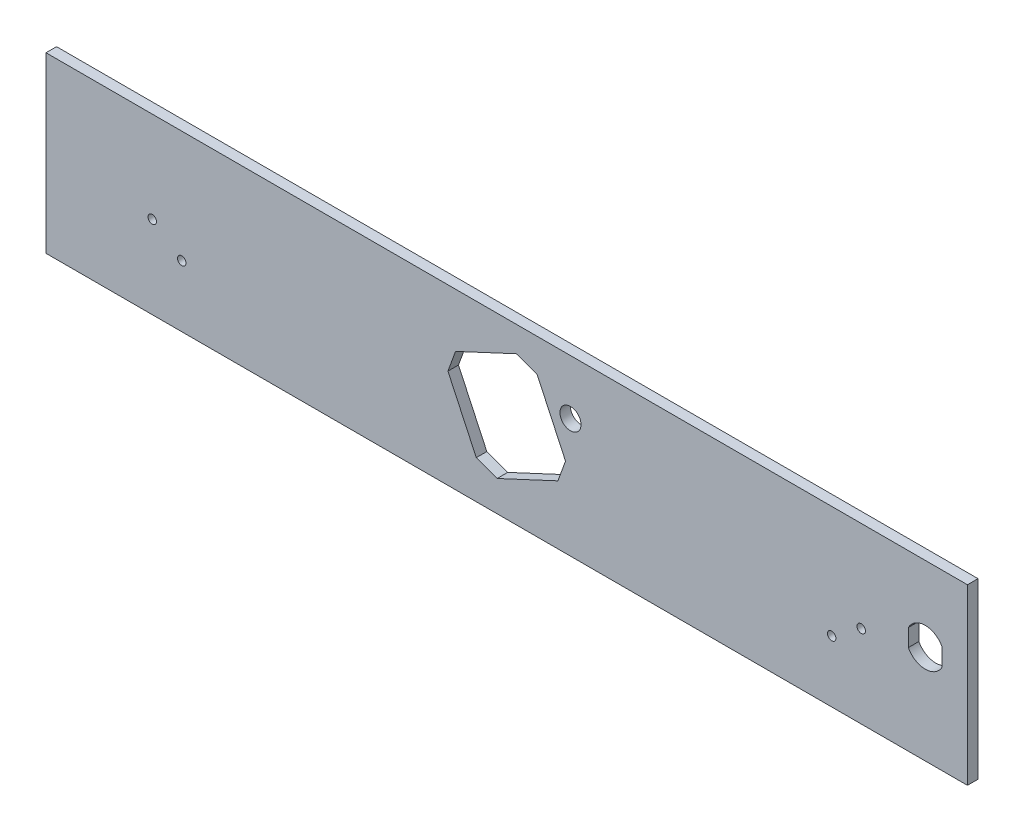
from build123d import *

# Parameters (mm, degrees)
SKETCH1_W           = 415.925
SKETCH1_H           = 78.4225
BOSS_EXTRUDE1_DEPTH = 4.7625
SKETCH2_R           = 1.905
CUT_EXTRUDE1_DEPTH  = 424.280492744
CUT_EXTRUDE2_DEPTH  = 424.280492744
SKETCH4_W           = 1.211538462
SKETCH4_H           = 0.583333334
CUT_EXTRUDE3_DEPTH  = 1.016
SKETCH5_R           = 4.7625
CUT_EXTRUDE4_DEPTH  = 424.280492862


with BuildPart() as part:
    # Sketch1 → Boss-Extrude1 (new body)
    with BuildSketch(Plane.XY):
        with Locations((207.9625, 39.21125)):
            Rectangle(SKETCH1_W, SKETCH1_H)
    extrude(amount=BOSS_EXTRUDE1_DEPTH)

    # Sketch2 → Cut-Extrude1 (cut, through all)
    with BuildSketch(Plane(origin=(0, 0, 0), x_dir=(-1, 0, 0), z_dir=(0, 0, -1))):
        with Locations((-367.9825, 37.30625)):
            Circle(SKETCH2_R)
        with Locations((-354.6475, 27.78125)):
            Circle(SKETCH2_R)
        with Locations((-47.9425, 37.30625)):
            Circle(SKETCH2_R)
        with Locations((-61.2775, 27.78125)):
            Circle(SKETCH2_R)
    extrude(amount=-CUT_EXTRUDE1_DEPTH, mode=Mode.SUBTRACT)

    # Sketch3 → Cut-Extrude2 (cut, through all)
    with BuildSketch(Plane.XY.offset(4.7625)):
        with BuildLine():
            ThreePointArc((404.495, 48.377258108), (396.875, 53.0225), (389.255, 48.377258108))
            Line((389.255, 48.377258108), (389.255, 40.522741892))
            ThreePointArc((389.255, 40.522741892), (396.875, 35.8775), (404.495, 40.522741892))
            Line((404.495, 40.522741892), (404.495, 48.377258108))
        make_face()
    extrude(amount=-CUT_EXTRUDE2_DEPTH, mode=Mode.SUBTRACT)

    # Sketch4 → Cut-Extrude3 (cut)
    # profile 1 of 9: a face of its own
    with BuildSketch(Plane.XY):
        Polygon((43.775641026, 9.85), (43.147435897, 9.85), (43.147435897, 6.978205128), (42.16025641, 6.978205128), (42.16025641, 6.35), (43.775641026, 6.35), align=None)
    # profile 2 of 9: a face of its own
    with BuildSketch(Plane.XY):
        with BuildLine():
            Line((38.480769231, 9.242828526), (38.94140625, 8.802524038))
            add(Edge.make_bspline(
                [(38.94140625, 8.802524038), (38.980481235, 8.842927638), (39.056806922, 8.921848526), (39.179796327, 9.026332827), (39.30770083, 9.113406355), (39.438032304, 9.186739125), (39.573135035, 9.242220593), (39.711446867, 9.282650872), (39.853850963, 9.307299686), (39.950224577, 9.310119946), (39.998697917, 9.311538462)],
                knots=[0, 0, 0, 0, 1.115251505, 2.178435587, 3.19620269, 4.182487026, 5.141301733, 6.088180966, 7.038406374, 8, 8, 8, 8], degree=3))
            add(Edge.make_bspline(
                [(39.998697917, 9.311538462), (40.039179046, 9.310417785), (40.119064094, 9.308206253), (40.236356279, 9.291993543), (40.348552316, 9.264423124), (40.456036269, 9.226425979), (40.558491863, 9.17725969), (40.656133908, 9.116962311), (40.748721672, 9.046078413), (40.835032124, 8.964974752), (40.913985892, 8.876362907), (40.983746573, 8.781814281), (41.042182334, 8.681545478), (41.090139613, 8.576571947), (41.127496479, 8.466407818), (41.154173975, 8.35112726), (41.169603525, 8.23059298), (41.171906489, 8.148654675), (41.173076923, 8.107011218)],
                knots=[0, 0, 0, 0, 1.035432265, 2.043311493, 3.022114605, 3.98653278, 4.95457646, 5.923598177, 6.917315552, 7.932509744, 8.948865224, 9.949768934, 10.933144597, 11.912367597, 12.897413939, 13.903909035, 14.934704909, 16, 16, 16, 16], degree=3))
            add(Edge.make_bspline(
                [(41.173076923, 8.107011218), (41.172739617, 8.077782926), (41.172074781, 8.020173362), (41.16479697, 7.934952828), (41.153077977, 7.852268764), (41.136117692, 7.772246412), (41.114908688, 7.694816425), (41.090025698, 7.61931082), (41.058810352, 7.546772912), (41.024160848, 7.476360221), (40.983863874, 7.409994047), (40.940416301, 7.346708391), (40.893304503, 7.286813475), (40.842223332, 7.23055415), (40.786453885, 7.178809624), (40.727437596, 7.130023877), (40.664178942, 7.085418182), (40.597991965, 7.04387311), (40.528304893, 7.007782552), (40.457008498, 6.975091479), (40.383021783, 6.948541467), (40.307245581, 6.927139735), (40.22995069, 6.908940759), (40.150381092, 6.89773509), (40.069226558, 6.889249168), (40.014379715, 6.888725212), (39.986778846, 6.888461538)],
                knots=[0, 0, 0, 0, 1.103660481, 2.175337485, 3.227646561, 4.255952547, 5.262355991, 6.258840057, 7.255597736, 8.242457506, 9.22035537, 10.185017736, 11.140346927, 12.096287581, 13.051739095, 14.01125915, 14.986044842, 15.97314143, 16.960198552, 17.947847494, 18.933482797, 19.925264591, 20.920966487, 21.929612487, 22.958107872, 24, 24, 24, 24], degree=3))
            add(Edge.make_bspline(
                [(39.986778846, 6.888461538), (39.939963029, 6.8898157), (39.847982123, 6.892476276), (39.712986917, 6.913281603), (39.584349935, 6.947505189), (39.481569602, 6.987921255), (39.401043925, 7.027832645), (39.339740919, 7.064748715), (39.276348831, 7.106043392), (39.211920552, 7.153275183), (39.145731391, 7.205877287), (39.07894974, 7.265001788), (39.009865975, 7.328701801), (38.964609885, 7.374165752), (38.94140625, 7.397475962)],
                knots=[0, 0, 0, 0, 1.404581149, 2.759636711, 4.088442092, 5.392261763, 6.066678138, 6.783632037, 7.538459478, 8.336747902, 9.180226004, 10.074962426, 11.012997595, 12, 12, 12, 12], degree=3))
            Line((38.94140625, 7.397475962), (38.494791667, 6.928425481))
            add(Edge.make_bspline(
                [(38.494791667, 6.928425481), (38.526186268, 6.898114979), (38.587461816, 6.838955361), (38.679894278, 6.754954225), (38.772210411, 6.679469865), (38.862180049, 6.609762532), (38.951276987, 6.547862968), (39.039491778, 6.493709355), (39.125825792, 6.445932068), (39.212071781, 6.405336849), (39.298766414, 6.370867291), (39.387965003, 6.341191265), (39.479940237, 6.316086414), (39.575253859, 6.295830096), (39.67301684, 6.279587264), (39.774144114, 6.268623446), (39.877994482, 6.261252837), (39.948437796, 6.260590526), (39.983974359, 6.26025641)],
                knots=[0, 0, 0, 0, 1.244526981, 2.429050516, 3.560637417, 4.644440555, 5.67424972, 6.652764056, 7.595344123, 8.486817594, 9.369275933, 10.254498637, 11.166417451, 12.086725134, 13.032340136, 13.991389299, 14.986715468, 16, 16, 16, 16], degree=3))
            add(Edge.make_bspline(
                [(39.983974359, 6.26025641), (40.049250623, 6.261920432), (40.176978127, 6.265176461), (40.364159453, 6.28930143), (40.541976689, 6.329746515), (40.71086243, 6.386947022), (40.870762974, 6.460017988), (41.021637415, 6.549599561), (41.163242575, 6.655453737), (41.294434564, 6.776339803), (41.413103962, 6.909848314), (41.517993967, 7.053199828), (41.604758983, 7.207098866), (41.676801845, 7.369271846), (41.733138416, 7.540458828), (41.772789812, 7.720844982), (41.797242538, 7.910256136), (41.799917701, 8.039628321), (41.801282051, 8.105608974)],
                knots=[0, 0, 0, 0, 1.078019885, 2.10938526, 3.111377082, 4.085535484, 5.04941344, 6.010039228, 6.978205633, 7.964457913, 8.951525778, 9.924444315, 10.892603023, 11.863865945, 12.85144698, 13.863884204, 14.910567087, 16, 16, 16, 16], degree=3))
            add(Edge.make_bspline(
                [(41.801282051, 8.105608974), (41.800705543, 8.148640994), (41.799563044, 8.233919938), (41.787555277, 8.359542733), (41.770815751, 8.482002487), (41.744260015, 8.600027663), (41.712249695, 8.715208277), (41.672440656, 8.826292451), (41.624896479, 8.933599451), (41.571149624, 9.037308917), (41.510346346, 9.13674144), (41.442422408, 9.231042737), (41.36912644, 9.320940799), (41.288697256, 9.405242959), (41.2023036, 9.484689407), (41.109555414, 9.558849608), (41.011010532, 9.628787103), (40.906402228, 9.692698373), (40.797762765, 9.750509514), (40.686462371, 9.801501409), (40.572774499, 9.844118891), (40.457179831, 9.879468521), (40.339189981, 9.905854519), (40.219647131, 9.925827869), (40.097534115, 9.936993099), (40.015545803, 9.938820919), (39.974158654, 9.93974359)],
                knots=[0, 0, 0, 0, 1.071919942, 2.124283339, 3.142214191, 4.149696895, 5.136002878, 6.119640489, 7.086990633, 8.058538607, 9.028339693, 9.988281803, 10.952401235, 11.916291999, 12.888973767, 13.874849856, 14.873389453, 15.898127285, 16.927174885, 17.938320013, 18.946391617, 19.950418109, 20.947802303, 21.956882652, 22.968648068, 24, 24, 24, 24], degree=3))
            add(Edge.make_bspline(
                [(39.974158654, 9.93974359), (39.938851172, 9.939214692), (39.868603307, 9.938162395), (39.763992448, 9.929390354), (39.660218217, 9.915613953), (39.557652159, 9.894828298), (39.455560616, 9.870153099), (39.355285185, 9.837844329), (39.255243968, 9.801830117), (39.157005961, 9.758782479), (39.060434039, 9.711792095), (38.967790552, 9.658479797), (38.877520024, 9.602126365), (38.791622796, 9.539396556), (38.708489827, 9.472565697), (38.628555828, 9.401321984), (38.552522265, 9.324477576), (38.504807823, 9.270182466), (38.480769231, 9.242828526)],
                knots=[0, 0, 0, 0, 0.996412454, 1.982464992, 2.961075852, 3.949442424, 4.934965278, 5.923860011, 6.921385422, 7.934793307, 8.949617135, 9.951082467, 10.950285876, 11.951772932, 12.951063433, 13.960125323, 14.972308753, 16, 16, 16, 16], degree=3))
        make_face()
    # profile 3 of 9: a face of its own
    with BuildSketch(Plane.XY):
        with BuildLine():
            Line((36.057692308, 9.382351763), (36.52744391, 8.952564103))
            add(Edge.make_bspline(
                [(36.52744391, 8.952564103), (36.547566055, 8.980948479), (36.586197766, 9.035442524), (36.64881574, 9.108411334), (36.711150962, 9.17065916), (36.77378093, 9.221925958), (36.837260772, 9.261900244), (36.901480295, 9.290202481), (36.966075423, 9.308194481), (37.009473377, 9.310434918), (37.030849359, 9.311538462)],
                knots=[0, 0, 0, 0, 1.299362458, 2.494594718, 3.587462134, 4.587049575, 5.512617175, 6.380583204, 7.202344345, 8, 8, 8, 8], degree=3))
            add(Edge.make_bspline(
                [(37.030849359, 9.311538462), (37.050788262, 9.310839206), (37.089285044, 9.309489126), (37.144165063, 9.296069437), (37.192888326, 9.272909025), (37.23540728, 9.242624837), (37.269088565, 9.206139412), (37.295980459, 9.167875583), (37.311122855, 9.125640968), (37.313115892, 9.096632532), (37.314102564, 9.082271635)],
                knots=[0, 0, 0, 0, 1.185010067, 2.2879431, 3.333075148, 4.379039566, 5.372662701, 6.27520591, 7.14612461, 8, 8, 8, 8], degree=3))
            add(Edge.make_bspline(
                [(37.314102564, 9.082271635), (37.313484267, 9.067703647), (37.312239103, 9.038365745), (37.300212509, 8.995367395), (37.282084998, 8.953353002), (37.264763421, 8.927776842), (37.255909455, 8.914703526)],
                knots=[0, 0, 0, 0, 0.967525499, 1.948461899, 2.951351359, 4, 4, 4, 4], degree=3))
            add(Edge.make_bspline(
                [(37.255909455, 8.914703526), (37.247860243, 8.904541774), (37.229332018, 8.881150764), (37.194002489, 8.84410305), (37.14963602, 8.798716357), (37.094525297, 8.746551401), (37.030958116, 8.685732126), (36.955988057, 8.618649361), (36.871773086, 8.543225631), (36.811915035, 8.490703276), (36.780548878, 8.46318109)],
                knots=[0, 0, 0, 0, 0.473873513, 1.090794244, 1.870441696, 2.795289791, 3.865433203, 5.087734844, 6.473946851, 8, 8, 8, 8], degree=3))
            add(Edge.make_bspline(
                [(36.780548878, 8.46318109), (36.751107228, 8.437700826), (36.695233092, 8.38934458), (36.615735292, 8.320710653), (36.545869966, 8.258962381), (36.484619336, 8.205026476), (36.432911902, 8.158337026), (36.390530284, 8.118670855), (36.356956864, 8.086800191), (36.337872341, 8.067550291), (36.329727564, 8.059334936)],
                knots=[0, 0, 0, 0, 1.543621617, 2.929473131, 4.163658386, 5.240097082, 6.164993805, 6.925417477, 7.541396219, 8, 8, 8, 8], degree=3))
            add(Edge.make_bspline(
                [(36.329727564, 8.059334936), (36.29882798, 8.025894968), (36.239428127, 7.961611605), (36.162229258, 7.861992611), (36.098692092, 7.764744159), (36.049538535, 7.668036363), (36.012415792, 7.570473922), (35.986243767, 7.469664122), (35.970569166, 7.364553564), (35.96882892, 7.292828439), (35.967948718, 7.256550481)],
                knots=[0, 0, 0, 0, 1.206664779, 2.319633467, 3.337109185, 4.282041471, 5.190008762, 6.099243693, 7.03861361, 8, 8, 8, 8], degree=3))
            add(Edge.make_bspline(
                [(35.967948718, 7.256550481), (35.968575223, 7.221202059), (35.96980445, 7.151847141), (35.984860117, 7.050356549), (36.006328616, 6.953225647), (36.039522681, 6.861511358), (36.07997941, 6.773708218), (36.130697764, 6.691183923), (36.190259516, 6.613103292), (36.258526428, 6.540862112), (36.33403774, 6.475308248), (36.415030799, 6.41695065), (36.502297595, 6.36876902), (36.595092535, 6.329094884), (36.693365947, 6.298537334), (36.797000759, 6.275952457), (36.906155487, 6.262397369), (36.980797062, 6.260980346), (37.018930288, 6.26025641)],
                knots=[0, 0, 0, 0, 1.043214005, 2.046824704, 3.02475056, 3.976699089, 4.921714032, 5.875962561, 6.831408892, 7.817874052, 8.806269674, 9.781291748, 10.760897367, 11.74438705, 12.757449933, 13.795994037, 14.874007457, 16, 16, 16, 16], degree=3))
            add(Edge.make_bspline(
                [(37.018930288, 6.26025641), (37.048864546, 6.260787464), (37.108151544, 6.261839255), (37.195531615, 6.270426251), (37.279906952, 6.284284751), (37.361182513, 6.30414812), (37.439724459, 6.329317702), (37.515536015, 6.360061383), (37.588093829, 6.396855678), (37.657946907, 6.43894395), (37.724755679, 6.487813977), (37.789364914, 6.542466629), (37.851132852, 6.603742487), (37.910356152, 6.671496636), (37.966655887, 6.74592094), (38.021874948, 6.825978902), (38.073559236, 6.91315629), (38.10548692, 6.974311933), (38.121794872, 7.005548878)],
                knots=[0, 0, 0, 0, 1.016823716, 2.013894106, 2.979844003, 3.91962641, 4.853723003, 5.779685073, 6.695824784, 7.614987388, 8.547259901, 9.504950863, 10.487499108, 11.500346958, 12.559593716, 13.656357062, 14.802919212, 16, 16, 16, 16], degree=3))
            Line((38.121794872, 7.005548878), (37.569310897, 7.337179487))
            add(Edge.make_bspline(
                [(37.569310897, 7.337179487), (37.548912087, 7.301721473), (37.509805823, 7.23374543), (37.443536604, 7.142411001), (37.375647172, 7.064198182), (37.304567985, 7.000489388), (37.231163338, 6.950432751), (37.15507867, 6.914658806), (37.076260527, 6.892514774), (37.022573188, 6.889810476), (36.995793269, 6.888461538)],
                knots=[0, 0, 0, 0, 1.283663364, 2.460892379, 3.537111102, 4.529833553, 5.449777664, 6.316464042, 7.160231139, 8, 8, 8, 8], degree=3))
            add(Edge.make_bspline(
                [(36.995793269, 6.888461538), (36.968554258, 6.889563154), (36.91570661, 6.891700449), (36.840273355, 6.911441996), (36.77111329, 6.942437673), (36.711331841, 6.98666423), (36.660712679, 7.037708399), (36.623352832, 7.094497371), (36.599883124, 7.155941668), (36.597401806, 7.198624918), (36.596153846, 7.220092147)],
                knots=[0, 0, 0, 0, 1.13588714, 2.203786484, 3.234766741, 4.283437687, 5.291419208, 6.222934724, 7.106237994, 8, 8, 8, 8], degree=3))
            add(Edge.make_bspline(
                [(36.596153846, 7.220092147), (36.597306286, 7.240063911), (36.599647359, 7.280634636), (36.616890974, 7.34095678), (36.643848006, 7.401251492), (36.675740074, 7.450706845), (36.708194248, 7.492114472), (36.739227757, 7.527992307), (36.777018363, 7.567631034), (36.821470244, 7.611080516), (36.871996075, 7.658723248), (36.928638418, 7.710554566), (36.992045887, 7.766117898), (37.036862411, 7.80396709), (37.060296474, 7.823758013)],
                knots=[0, 0, 0, 0, 0.916159276, 1.861089862, 2.860218735, 3.940849679, 4.552606315, 5.27541173, 6.11797699, 7.06649574, 8.129236253, 9.306560635, 10.591630461, 12, 12, 12, 12], degree=3))
            add(Edge.make_bspline(
                [(37.060296474, 7.823758013), (37.104845561, 7.861450812), (37.190348742, 7.933794702), (37.311175584, 8.04064435), (37.420051388, 8.140505137), (37.516035784, 8.23461156), (37.600351764, 8.321225691), (37.672428301, 8.401051045), (37.731473603, 8.474703364), (37.793606052, 8.561939606), (37.852644301, 8.668242962), (37.903670101, 8.796138223), (37.936773487, 8.924017255), (37.940482261, 9.009868194), (37.942307692, 9.052123397)],
                knots=[0, 0, 0, 0, 1.345494975, 2.582412109, 3.71882943, 4.751509156, 5.681369928, 6.505683931, 7.230279997, 7.856715994, 8.973648664, 10.023341002, 11.027102913, 12, 12, 12, 12], degree=3))
            add(Edge.make_bspline(
                [(37.942307692, 9.052123397), (37.941548498, 9.08208852), (37.940052803, 9.14112303), (37.926710976, 9.227924675), (37.906771107, 9.311680969), (37.877812692, 9.392086331), (37.840228166, 9.469040051), (37.79458322, 9.542918848), (37.740169073, 9.613042759), (37.678848003, 9.679365297), (37.611287883, 9.739976549), (37.53909131, 9.793472052), (37.462666922, 9.838655132), (37.382482245, 9.876137778), (37.298040408, 9.904828362), (37.209963489, 9.925165678), (37.11812516, 9.937261665), (37.05565871, 9.938905974), (37.023838141, 9.93974359)],
                knots=[0, 0, 0, 0, 1.010766082, 1.991317756, 2.957454644, 3.913069143, 4.869106762, 5.843196583, 6.838735724, 7.860187025, 8.887984031, 9.89767229, 10.887916223, 11.879572884, 12.879850636, 13.892031539, 14.926195476, 16, 16, 16, 16], degree=3))
            add(Edge.make_bspline(
                [(37.023838141, 9.93974359), (36.982600258, 9.93823502), (36.900450011, 9.935229789), (36.7789885, 9.911729864), (36.660349974, 9.874773756), (36.564748827, 9.830190278), (36.488680779, 9.787002242), (36.430381725, 9.747240139), (36.371059301, 9.701690512), (36.310235106, 9.650209824), (36.249039349, 9.59182811), (36.185731941, 9.527935192), (36.121175524, 9.457978887), (36.079224089, 9.408002427), (36.057692308, 9.382351763)],
                knots=[0, 0, 0, 0, 1.282922637, 2.555718331, 3.837320111, 5.142675274, 5.830281639, 6.55870424, 7.337177975, 8.157850921, 9.037902056, 9.96903443, 10.957596896, 12, 12, 12, 12], degree=3))
        make_face()
    # profile 4 of 9: a face of its own
    with BuildSketch(Plane.XY):
        Polygon((34.262119391, 9.85), (33.679487179, 9.85), (32.266025641, 6.35), (32.936999199, 6.35), (33.209034455, 7.067948718), (34.733974359, 7.067948718), (35.006009615, 6.35), (35.676282051, 6.35), align=None)
        Polygon((33.971153846, 8.911197917), (34.495592949, 7.696153846), (33.446714744, 7.696153846), align=None, mode=Mode.SUBTRACT)
    # profile 5 of 9: a face of its own
    with BuildSketch(Plane.XY):
        with BuildLine():
            Line((31.75, 9.85), (31.048878205, 9.85))
            add(Edge.make_bspline(
                [(31.048878205, 9.85), (31.003067817, 9.849794943), (30.914689975, 9.849399345), (30.787241855, 9.844602193), (30.669664725, 9.836005403), (30.561985597, 9.825381131), (30.464248747, 9.810486316), (30.376331777, 9.793410575), (30.298216444, 9.772607354), (30.229021881, 9.747914219), (30.166921996, 9.718801977), (30.108155475, 9.687795361), (30.054050449, 9.650790059), (30.001876074, 9.611774345), (29.954615248, 9.567021062), (29.909319558, 9.519508606), (29.867907401, 9.467352673), (29.830186887, 9.411184597), (29.795968569, 9.352042122), (29.766073157, 9.28981952), (29.741823673, 9.22441833), (29.721481371, 9.156261623), (29.705142236, 9.085352371), (29.694266388, 9.011254473), (29.686878965, 8.934485311), (29.686227126, 8.882236171), (29.685897436, 8.855809295)],
                knots=[0, 0, 0, 0, 1.698747864, 3.27724071, 4.728299578, 6.070144658, 7.288476769, 8.393259625, 9.389771311, 10.283485332, 11.113357557, 11.931608583, 12.74405601, 13.541433047, 14.344816069, 15.154114104, 15.974336324, 16.810834471, 17.661136416, 18.50621059, 19.367396281, 20.244825668, 21.142564693, 22.063065223, 23.020325768, 24, 24, 24, 24], degree=3))
            add(Edge.make_bspline(
                [(29.685897436, 8.855809295), (29.686374457, 8.826573871), (29.687311861, 8.769122669), (29.696501448, 8.684906257), (29.712200165, 8.604613532), (29.732717566, 8.527567372), (29.761327624, 8.455035358), (29.794013271, 8.385286853), (29.834226985, 8.320277391), (29.880177582, 8.259193782), (29.930360876, 8.201539387), (29.985968216, 8.148978868), (30.045939703, 8.101153923), (30.109928184, 8.057563341), (30.178173889, 8.018295054), (30.250627576, 7.982981357), (30.327784001, 7.952751692), (30.381513414, 7.936941821), (30.408754006, 7.928926282)],
                knots=[0, 0, 0, 0, 1.102006807, 2.165578795, 3.188629044, 4.184801286, 5.166646146, 6.124351954, 7.085497154, 8.042432466, 9.003981491, 9.963833307, 10.922997304, 11.89326795, 12.880200226, 13.889073926, 14.929769137, 16, 16, 16, 16], degree=3))
            add(Edge.make_bspline(
                [(30.408754006, 7.928926282), (30.426696227, 7.924462228), (30.465564856, 7.914791651), (30.529881759, 7.904973587), (30.604000238, 7.895946482), (30.688159965, 7.888188777), (30.782409461, 7.882915346), (30.886657467, 7.87879703), (31.000951227, 7.87580259), (31.080426588, 7.875696334), (31.121794872, 7.875641026)],
                knots=[0, 0, 0, 0, 0.618981996, 1.340914327, 2.176866532, 3.120127938, 4.170906482, 5.338178032, 6.614476169, 8, 8, 8, 8], degree=3))
            Line((31.121794872, 7.875641026), (31.121794872, 6.35))
            Line((31.121794872, 6.35), (31.75, 6.35))
            Line((31.75, 6.35), (31.75, 9.85))
        make_face()
        with BuildLine():
            Line((31.121794872, 8.503846154), (30.899539263, 8.503846154))
            add(Edge.make_bspline(
                [(30.899539263, 8.503846154), (30.859096346, 8.504102593), (30.784680778, 8.504574446), (30.68305539, 8.511397707), (30.601387274, 8.521818204), (30.536867946, 8.536763608), (30.485923825, 8.559445236), (30.441987711, 8.585683609), (30.404302583, 8.618861312), (30.37167281, 8.656772514), (30.345586289, 8.700334385), (30.327496646, 8.748837605), (30.315745969, 8.801263069), (30.314660685, 8.837747722), (30.314102564, 8.856510417)],
                knots=[0, 0, 0, 0, 1.8619151, 3.425951444, 4.686033666, 5.651700536, 6.461346321, 7.243864085, 7.999046032, 8.762387399, 9.539336099, 10.322741239, 11.137448474, 12, 12, 12, 12], degree=3))
            add(Edge.make_bspline(
                [(30.314102564, 8.856510417), (30.314654944, 8.872903138), (30.315726694, 8.904708959), (30.323600062, 8.950612649), (30.336147946, 8.993404356), (30.354329347, 9.03263718), (30.377833594, 9.068244457), (30.406490027, 9.100212159), (30.439930929, 9.129224904), (30.46574926, 9.144581793), (30.478866186, 9.152383814)],
                knots=[0, 0, 0, 0, 1.102301479, 2.1387299, 3.123554645, 4.094223062, 5.036071848, 5.982632524, 6.975082478, 8, 8, 8, 8], degree=3))
            add(Edge.make_bspline(
                [(30.478866186, 9.152383814), (30.489976979, 9.158002861), (30.513500806, 9.169899535), (30.553564164, 9.183730288), (30.599796666, 9.195398051), (30.652510436, 9.205082183), (30.711495182, 9.212598074), (30.77674038, 9.218345851), (30.848342046, 9.220657256), (30.89813672, 9.221405207), (30.924078526, 9.221794872)],
                knots=[0, 0, 0, 0, 0.656809284, 1.390599849, 2.23162475, 3.173112763, 4.218524733, 5.370385145, 6.63003504, 8, 8, 8, 8], degree=3))
            Line((30.924078526, 9.221794872), (31.121794872, 9.221794872))
            Line((31.121794872, 9.221794872), (31.121794872, 8.503846154))
        make_face(mode=Mode.SUBTRACT)
    # profile 6 of 9: a face of its own
    with BuildSketch(Plane.XY):
        with Locations((28.451923077, 7.628846154)):
            Rectangle(SKETCH4_W, SKETCH4_H)
    # profile 7 of 9: a face of its own
    with BuildSketch(Plane.XY):
        with BuildLine():
            Line((26.065304487, 9.93974359), (25.509314904, 9.657892628))
            Line((25.509314904, 9.657892628), (26.119290865, 8.458974359))
            add(Edge.make_bspline(
                [(26.119290865, 8.458974359), (26.083254058, 8.458041348), (26.012273656, 8.456203629), (25.907840397, 8.441350882), (25.808000257, 8.415674043), (25.711746553, 8.381639463), (25.620255895, 8.335930683), (25.532054775, 8.281557705), (25.449425001, 8.21524401), (25.370471942, 8.141771954), (25.298680331, 8.060375475), (25.236316625, 7.972912373), (25.181967756, 7.881510636), (25.139719132, 7.784125384), (25.105639986, 7.68237089), (25.081050382, 7.575840396), (25.067021324, 7.464225415), (25.065087185, 7.388400302), (25.064102564, 7.349799679)],
                knots=[0, 0, 0, 0, 1.013260694, 1.995783107, 2.958651975, 3.908806537, 4.861209129, 5.829647963, 6.817170299, 7.835534541, 8.860094905, 9.863329007, 10.853101798, 11.844815043, 12.84250023, 13.867713965, 14.914507806, 16, 16, 16, 16], degree=3))
            add(Edge.make_bspline(
                [(25.064102564, 7.349799679), (25.065025235, 7.312591021), (25.066848961, 7.239045459), (25.081924466, 7.131025732), (25.106287273, 7.027387122), (25.141106618, 6.928336607), (25.185364821, 6.833390025), (25.239489605, 6.742603092), (25.30392983, 6.656654229), (25.37702054, 6.576000127), (25.456921295, 6.502483317), (25.541141042, 6.437137297), (25.63039345, 6.383159006), (25.722991543, 6.337573073), (25.820640109, 6.303556092), (25.921877832, 6.277879165), (26.027472427, 6.263062463), (26.099147333, 6.261199246), (26.135416667, 6.26025641)],
                knots=[0, 0, 0, 0, 1.049934834, 2.075270938, 3.072134561, 4.05064612, 5.033440221, 6.024524368, 7.028587226, 8.060776465, 9.092543989, 10.090062252, 11.064205434, 12.031961459, 12.998029633, 13.977230324, 14.976426867, 16, 16, 16, 16], degree=3))
            add(Edge.make_bspline(
                [(26.135416667, 6.26025641), (26.173343368, 6.261030145), (26.247921094, 6.26255159), (26.357046971, 6.279587767), (26.46170808, 6.305233356), (26.561316207, 6.3418509), (26.656490786, 6.388476396), (26.746111308, 6.446170758), (26.830932701, 6.514297771), (26.910050646, 6.591324685), (26.981330018, 6.675697131), (27.044905261, 6.763297697), (27.098689998, 6.854263848), (27.142227489, 6.948498322), (27.17619645, 7.045700839), (27.199831918, 7.14605588), (27.215232606, 7.249297254), (27.217037986, 7.319362693), (27.217948718, 7.354707532)],
                knots=[0, 0, 0, 0, 1.063775006, 2.091769615, 3.092589432, 4.084662827, 5.064601646, 6.061867366, 7.070035304, 8.113879863, 9.156342271, 10.166834137, 11.149076039, 12.117706134, 13.076241869, 14.034148791, 15.008317125, 16, 16, 16, 16], degree=3))
            add(Edge.make_bspline(
                [(27.217948718, 7.354707532), (27.217467505, 7.382077976), (27.2165024, 7.436971218), (27.206803676, 7.519170865), (27.192058209, 7.601586278), (27.174966282, 7.671131014), (27.157366743, 7.729938366), (27.139652671, 7.779705439), (27.117699982, 7.834936007), (27.092604806, 7.895771109), (27.063577992, 7.962137558), (27.030771171, 8.033854458), (26.994102669, 8.111464902), (26.967952976, 8.16477126), (26.954326923, 8.192548077)],
                knots=[0, 0, 0, 0, 1.110454016, 2.227089276, 3.35462975, 4.507227546, 5.131400587, 5.845402449, 6.650387134, 7.543487832, 8.516250726, 9.590168902, 10.744287919, 12, 12, 12, 12], degree=3))
            Line((26.954326923, 8.192548077), (26.065304487, 9.93974359))
        make_face()
        with BuildLine():
            add(Edge.make_bspline(
                [(26.149439103, 7.875641026), (26.179582297, 7.874258421), (26.238568571, 7.871552845), (26.322438231, 7.843218739), (26.398908332, 7.798769578), (26.465193561, 7.736865525), (26.520635057, 7.662887751), (26.561375413, 7.578506218), (26.585883001, 7.484846975), (26.588429183, 7.419361994), (26.58974359, 7.385556891)],
                knots=[0, 0, 0, 0, 0.981744412, 1.921144944, 2.858899012, 3.85339082, 4.86292663, 5.863643845, 6.897155691, 8, 8, 8, 8], degree=3))
            add(Edge.make_bspline(
                [(26.58974359, 7.385556891), (26.588187291, 7.351740531), (26.585160185, 7.285965451), (26.559731079, 7.191414405), (26.518095742, 7.105116665), (26.459704838, 7.030158525), (26.391154756, 6.967937465), (26.315140845, 6.921922016), (26.232931045, 6.893653216), (26.176064519, 6.890204047), (26.147335737, 6.888461538)],
                knots=[0, 0, 0, 0, 1.098279937, 2.136227893, 3.159405121, 4.194678092, 5.206500211, 6.154139736, 7.067477469, 8, 8, 8, 8], degree=3))
            add(Edge.make_bspline(
                [(26.147335737, 6.888461538), (26.116994896, 6.890235082), (26.057491238, 6.89371331), (25.971653308, 6.920792611), (25.893239844, 6.96603715), (25.823907174, 7.028059004), (25.764351728, 7.102161771), (25.723145376, 7.188966412), (25.696540671, 7.284199894), (25.693750321, 7.351013724), (25.692307692, 7.385556891)],
                knots=[0, 0, 0, 0, 0.96921794, 1.900804717, 2.848419905, 3.844199796, 4.861108892, 5.867439427, 6.897452859, 8, 8, 8, 8], degree=3))
            add(Edge.make_bspline(
                [(25.692307692, 7.385556891), (25.69395111, 7.419342255), (25.697133779, 7.484771558), (25.7210394, 7.578869573), (25.763721271, 7.662925868), (25.820417175, 7.737170894), (25.888983591, 7.799047343), (25.968514181, 7.843569279), (26.056215147, 7.871502646), (26.11791138, 7.874241453), (26.149439103, 7.875641026)],
                knots=[0, 0, 0, 0, 1.083229974, 2.097801324, 3.086792542, 4.086858909, 5.079819718, 6.026392613, 6.991456328, 8, 8, 8, 8], degree=3))
        make_face(mode=Mode.SUBTRACT)
    # profile 8 of 9: a face of its own
    with BuildSketch(Plane.XY):
        with BuildLine():
            add(Edge.make_bspline(
                [(23.436798878, 9.93974359), (23.406391143, 9.939292178), (23.34660141, 9.938404583), (23.258542389, 9.928791201), (23.173717204, 9.914268063), (23.09179401, 9.894013349), (23.013362498, 9.867206957), (22.937851827, 9.835120165), (22.866160792, 9.796069956), (22.797375104, 9.751960738), (22.73152126, 9.702022851), (22.670182009, 9.64509108), (22.612237168, 9.58247543), (22.558941028, 9.513229263), (22.50911333, 9.437982447), (22.462917801, 9.35672305), (22.420708077, 9.269053361), (22.382011089, 9.174815174), (22.34740812, 9.072595899), (22.318262082, 8.961223037), (22.293264478, 8.840671153), (22.272164736, 8.710640176), (22.256216741, 8.570957264), (22.245467472, 8.421715214), (22.238090814, 8.263201744), (22.237488783, 8.154462806), (22.237179487, 8.098597756)],
                knots=[0, 0, 0, 0, 0.879237366, 1.728815576, 2.559023295, 3.367336655, 4.166867292, 4.954216142, 5.737608147, 6.525189134, 7.316157332, 8.124696809, 8.942788509, 9.781158001, 10.649253743, 11.551476218, 12.482711956, 13.461909668, 14.496590415, 15.601789533, 16.789733467, 18.056700938, 19.410929216, 20.8549011, 22.384193279, 24, 24, 24, 24], degree=3))
            add(Edge.make_bspline(
                [(22.237179487, 8.098597756), (22.237513753, 8.042033772), (22.238163224, 7.932130965), (22.245160822, 7.77216765), (22.257211017, 7.621842014), (22.272742177, 7.481169608), (22.294015618, 7.350224719), (22.318929775, 7.228668289), (22.348535875, 7.116544378), (22.384278654, 7.014105625), (22.422741408, 6.919701935), (22.465066594, 6.832203181), (22.510516488, 6.751372369), (22.558048608, 6.675990055), (22.61026884, 6.608278471), (22.664635477, 6.545935071), (22.723515739, 6.491334593), (22.784430541, 6.441663175), (22.849611437, 6.398737102), (22.918386235, 6.361194666), (22.991981069, 6.330743291), (23.069054431, 6.304258312), (23.150920052, 6.285244955), (23.236277098, 6.27015848), (23.326089234, 6.261820769), (23.387236953, 6.260786421), (23.418569712, 6.26025641)],
                knots=[0, 0, 0, 0, 1.643780988, 3.193836972, 4.651895693, 6.025988579, 7.305620092, 8.505800249, 9.631074763, 10.672816429, 11.65661981, 12.592235626, 13.49536222, 14.350718032, 15.179365177, 15.97804903, 16.751647189, 17.51006938, 18.259804725, 19.016521909, 19.783502495, 20.571750527, 21.382245291, 22.22305063, 23.089471752, 24, 24, 24, 24], degree=3))
            add(Edge.make_bspline(
                [(23.418569712, 6.26025641), (23.449901624, 6.260796645), (23.511280381, 6.261854957), (23.601335378, 6.270096486), (23.687144773, 6.28530607), (23.769658083, 6.304404282), (23.848301026, 6.33068469), (23.923450695, 6.362047148), (23.994529252, 6.399355338), (24.061733503, 6.442381425), (24.124833993, 6.491720504), (24.184811305, 6.546844838), (24.241532764, 6.607614701), (24.294135496, 6.674710765), (24.343480983, 6.747237439), (24.389054628, 6.826022941), (24.430829044, 6.910952561), (24.470110941, 7.002144684), (24.504241937, 7.10156257), (24.534616939, 7.210094009), (24.559499341, 7.3286437), (24.579511434, 7.457173557), (24.595489078, 7.595411285), (24.607374609, 7.743423606), (24.614411075, 7.901279462), (24.615053736, 8.009781655), (24.615384615, 8.065645032)],
                knots=[0, 0, 0, 0, 0.917216111, 1.796812873, 2.643793957, 3.46689424, 4.273913431, 5.068098542, 5.848489301, 6.620921603, 7.401012384, 8.190319798, 9.003608147, 9.831726257, 10.68377682, 11.569763213, 12.493818149, 13.453288342, 14.474581811, 15.568529029, 16.750744269, 18.018426408, 19.375425659, 20.823733699, 22.36466933, 24, 24, 24, 24], degree=3))
            add(Edge.make_bspline(
                [(24.615384615, 8.065645032), (24.614785258, 8.143262797), (24.613628789, 8.293027275), (24.598973169, 8.509393402), (24.577462435, 8.709386406), (24.545868263, 8.892671749), (24.506802506, 9.059928265), (24.45677677, 9.210054156), (24.399826109, 9.345126752), (24.351296829, 9.425144571), (24.327924679, 9.463681891)],
                knots=[0, 0, 0, 0, 1.288568992, 2.486310467, 3.599230591, 4.627010532, 5.572937695, 6.447898582, 7.252493626, 8, 8, 8, 8], degree=3))
            add(Edge.make_bspline(
                [(24.327924679, 9.463681891), (24.300748658, 9.501540942), (24.24761418, 9.575562848), (24.15470706, 9.672739774), (24.054890456, 9.755850239), (23.946114192, 9.82301338), (23.830098609, 9.875978238), (23.705847656, 9.913386721), (23.573820169, 9.935182647), (23.483154692, 9.938200572), (23.436798878, 9.93974359)],
                knots=[0, 0, 0, 0, 1.058512271, 2.069600068, 3.047294572, 4.004278952, 4.967380941, 5.939006123, 6.946246673, 8, 8, 8, 8], degree=3))
        make_face()
        with BuildLine():
            add(Edge.make_bspline(
                [(23.421374199, 9.311538462), (23.448863044, 9.310235545), (23.502755772, 9.307681137), (23.580956689, 9.285997815), (23.654695271, 9.252506756), (23.71078624, 9.212205503), (23.752769773, 9.173571918), (23.782103969, 9.138609781), (23.810392177, 9.099594555), (23.835377747, 9.054765685), (23.858970647, 9.005733924), (23.882028022, 8.952276698), (23.900929015, 8.893080981), (23.91949874, 8.829154885), (23.935767551, 8.758731022), (23.949397248, 8.681233756), (23.961574185, 8.596159114), (23.970067743, 8.503451372), (23.977986289, 8.403207526), (23.983662677, 8.295204271), (23.986035832, 8.179470744), (23.986790186, 8.099766781), (23.987179487, 8.058633814)],
                knots=[0, 0, 0, 0, 1.076674018, 2.110852608, 3.161083442, 4.239746716, 4.804137807, 5.395870207, 6.026861976, 6.692161227, 7.405688833, 8.16177676, 8.973626916, 9.841385931, 10.773283133, 11.807421078, 12.927755683, 14.143907515, 15.458935494, 16.872852025, 18.386167141, 20, 20, 20, 20], degree=3))
            add(Edge.make_bspline(
                [(23.987179487, 8.058633814), (23.986538745, 8.005344067), (23.985310075, 7.903157026), (23.978874876, 7.756208503), (23.965976054, 7.622473515), (23.949932523, 7.501045689), (23.927398728, 7.392712518), (23.901472139, 7.29644907), (23.869455107, 7.21348247), (23.832453257, 7.142612834), (23.791472041, 7.082324181), (23.746985128, 7.031078555), (23.700507138, 6.986702261), (23.650587343, 6.950655944), (23.597344835, 6.923031708), (23.541224092, 6.903161936), (23.48218945, 6.890998822), (23.441763136, 6.889312189), (23.421374199, 6.888461538)],
                knots=[0, 0, 0, 0, 1.771748488, 3.397459088, 4.888034009, 6.237357457, 7.467047327, 8.564189669, 9.548206622, 10.417051504, 11.216568818, 11.965764335, 12.669334354, 13.348544111, 14.005342236, 14.656555988, 15.322436492, 16, 16, 16, 16], degree=3))
            add(Edge.make_bspline(
                [(23.421374199, 6.888461538), (23.401684945, 6.889043617), (23.363135835, 6.890183253), (23.3069226, 6.901881469), (23.25376337, 6.920900227), (23.20381865, 6.947803595), (23.156909795, 6.982015344), (23.113266066, 7.023685815), (23.073216616, 7.073230366), (23.049883624, 7.109999749), (23.037860577, 7.128946314)],
                knots=[0, 0, 0, 0, 0.992283464, 1.942767638, 2.88273346, 3.832339453, 4.79467288, 5.803907806, 6.868395428, 8, 8, 8, 8], degree=3))
            add(Edge.make_bspline(
                [(23.037860577, 7.128946314), (23.023705464, 7.154836189), (22.99402334, 7.209125158), (22.959675134, 7.300735767), (22.930762729, 7.404057394), (22.905878245, 7.519411585), (22.888858776, 7.64725331), (22.87420163, 7.786771915), (22.867132124, 7.938669958), (22.86598223, 8.04390547), (22.865384615, 8.098597756)],
                knots=[0, 0, 0, 0, 0.710965849, 1.490837728, 2.352621235, 3.297892224, 4.334225155, 5.461620853, 6.680770821, 8, 8, 8, 8], degree=3))
            add(Edge.make_bspline(
                [(22.865384615, 8.098597756), (22.865615461, 8.153764798), (22.8660598, 8.259951935), (22.874212127, 8.412396063), (22.885564865, 8.551628473), (22.902170643, 8.677338316), (22.923536996, 8.789830761), (22.949871106, 8.889098454), (22.980917063, 8.975337033), (23.017733867, 9.048460505), (23.058510766, 9.110605426), (23.101796689, 9.163920947), (23.147774667, 9.209440394), (23.196367809, 9.247335064), (23.24870082, 9.276289435), (23.303774073, 9.296733616), (23.361700471, 9.309101659), (23.401214475, 9.310715231), (23.421374199, 9.311538462)],
                knots=[0, 0, 0, 0, 1.793836731, 3.452829483, 4.963243077, 6.335886805, 7.574563692, 8.684454726, 9.672768357, 10.54971625, 11.340229787, 12.085688095, 12.778991901, 13.440269426, 14.083255152, 14.715733572, 15.344777694, 16, 16, 16, 16], degree=3))
        make_face(mode=Mode.SUBTRACT)
    # profile 9 of 9: a face of its own
    with BuildSketch(Plane.XY):
        with BuildLine():
            Line((21.25, 8.683333333), (21.878205128, 8.683333333))
            add(Edge.make_bspline(
                [(21.878205128, 8.683333333), (21.875492007, 8.730853728), (21.87019073, 8.823705726), (21.849103591, 8.958576225), (21.820847549, 9.086014017), (21.783136109, 9.205573308), (21.735749217, 9.317210656), (21.679906261, 9.421306638), (21.614180579, 9.517313186), (21.53997103, 9.604767303), (21.458537488, 9.683223199), (21.371570593, 9.752787125), (21.27774007, 9.810189525), (21.178760279, 9.857426387), (21.074648073, 9.895166444), (20.964418389, 9.920398727), (20.849025654, 9.937486275), (20.770029983, 9.938981504), (20.729767628, 9.93974359)],
                knots=[0, 0, 0, 0, 1.199038563, 2.342849363, 3.436047546, 4.486744587, 5.497670872, 6.488682221, 7.459191391, 8.424610317, 9.374430501, 10.305433194, 11.225809216, 12.140057399, 13.06607119, 14.010487599, 14.985989317, 16, 16, 16, 16], degree=3))
            add(Edge.make_bspline(
                [(20.729767628, 9.93974359), (20.680346159, 9.93820151), (20.583863868, 9.935191008), (20.443667448, 9.909510428), (20.312739319, 9.866555691), (20.191174656, 9.806536594), (20.080008358, 9.730288623), (19.979258862, 9.639375396), (19.891972991, 9.531889507), (19.817597328, 9.412303267), (19.755800041, 9.28567827), (19.712495077, 9.154742772), (19.68403119, 9.02297127), (19.68099534, 8.934243011), (19.679487179, 8.890164263)],
                knots=[0, 0, 0, 0, 1.075374347, 2.099382735, 3.09057751, 4.06680945, 5.040638231, 6.016817125, 7.011024321, 8.044445721, 9.0776792, 10.070479129, 11.0414456, 12, 12, 12, 12], degree=3))
            add(Edge.make_bspline(
                [(19.679487179, 8.890164263), (19.680074378, 8.863502321), (19.681256262, 8.809838418), (19.689474063, 8.728631761), (19.701802388, 8.645913287), (19.720390498, 8.561753919), (19.743571394, 8.476130065), (19.771693172, 8.388785484), (19.805408144, 8.300215386), (19.844153676, 8.209422931), (19.890377193, 8.116113351), (19.944198053, 8.018887899), (20.007044785, 7.917832821), (20.078158279, 7.812377529), (20.157883915, 7.70268834), (20.246610889, 7.589095673), (20.343317274, 7.471199265), (20.411952515, 7.392392132), (20.447215545, 7.351903045)],
                knots=[0, 0, 0, 0, 0.728284026, 1.46585585, 2.227944881, 3.01186502, 3.81876927, 4.650621989, 5.517437689, 6.406905708, 7.346299482, 8.360816762, 9.441613733, 10.596154504, 11.834900912, 13.145207542, 14.533280747, 16, 16, 16, 16], degree=3))
            Line((20.447215545, 7.351903045), (20.8125, 6.933333333))
            Line((20.8125, 6.933333333), (19.634615385, 6.933333333))
            Line((19.634615385, 6.933333333), (19.634615385, 6.35))
            Line((19.634615385, 6.35), (21.967948718, 6.35))
            Line((21.967948718, 6.35), (21.967948718, 6.668309295))
            Line((21.967948718, 6.668309295), (20.931690705, 7.771173878))
            add(Edge.make_bspline(
                [(20.931690705, 7.771173878), (20.901688373, 7.803344781), (20.843582752, 7.865650278), (20.760904442, 7.95715253), (20.686087875, 8.043985982), (20.620684433, 8.127075237), (20.561261828, 8.203725216), (20.510469709, 8.276246247), (20.467843368, 8.343982712), (20.421566429, 8.425661059), (20.377618549, 8.523077022), (20.337293709, 8.635304206), (20.312712929, 8.742567547), (20.309320004, 8.812462646), (20.307692308, 8.84599359)],
                knots=[0, 0, 0, 0, 1.246127091, 2.413378631, 3.493388633, 4.492180848, 5.408488754, 6.240484944, 6.999099869, 7.674939598, 8.898438119, 10.020720584, 11.050475521, 12, 12, 12, 12], degree=3))
            add(Edge.make_bspline(
                [(20.307692308, 8.84599359), (20.308909297, 8.878432191), (20.311267408, 8.941287182), (20.337181141, 9.030698073), (20.377327596, 9.111650506), (20.43389962, 9.181725534), (20.502426059, 9.239310831), (20.581614797, 9.282141156), (20.670820212, 9.306854058), (20.733354907, 9.309947231), (20.76552484, 9.311538462)],
                knots=[0, 0, 0, 0, 1.062038974, 2.057870785, 3.028805853, 4.01125022, 4.991535629, 5.949134679, 6.94496649, 8, 8, 8, 8], degree=3))
            add(Edge.make_bspline(
                [(20.76552484, 9.311538462), (20.782144237, 9.310950642), (20.814862189, 9.309793424), (20.862955021, 9.302090139), (20.908718805, 9.288513903), (20.952662919, 9.270323658), (20.99431838, 9.246212358), (21.033580118, 9.216491338), (21.070861805, 9.181915879), (21.105992454, 9.142594092), (21.137965931, 9.098710967), (21.166364656, 9.050667285), (21.189845674, 8.99849287), (21.210519216, 8.942876502), (21.22646364, 8.883220817), (21.238073159, 8.819882848), (21.246899101, 8.752965636), (21.248947563, 8.706966346), (21.25, 8.683333333)],
                knots=[0, 0, 0, 0, 0.903469896, 1.778625579, 2.63899355, 3.493148037, 4.358286772, 5.247621495, 6.164656832, 7.118446693, 8.109501108, 9.111810964, 10.146451449, 11.215617525, 12.33435995, 13.498009769, 14.714554818, 16, 16, 16, 16], degree=3))
        make_face()
    extrude(amount=CUT_EXTRUDE3_DEPTH, mode=Mode.SUBTRACT)

    # Sketch5 → Cut-Extrude4 (cut, through all)
    with BuildSketch(Plane.XY.offset(4.7625)):
        with Locations((236.737772238, 53.77237981)):
            Circle(SKETCH5_R)
        Polygon((184.854775323, 54.101515269), (212.284842943, 66.892365864), (221.709765269, 63.461974677), (234.500615864, 36.031907057), (231.070224677, 26.606984731), (203.640157057, 13.816134136), (194.215234731, 17.246525323), (181.424384136, 44.676592943), align=None)
    extrude(amount=-CUT_EXTRUDE4_DEPTH, mode=Mode.SUBTRACT)


solid = part.part
